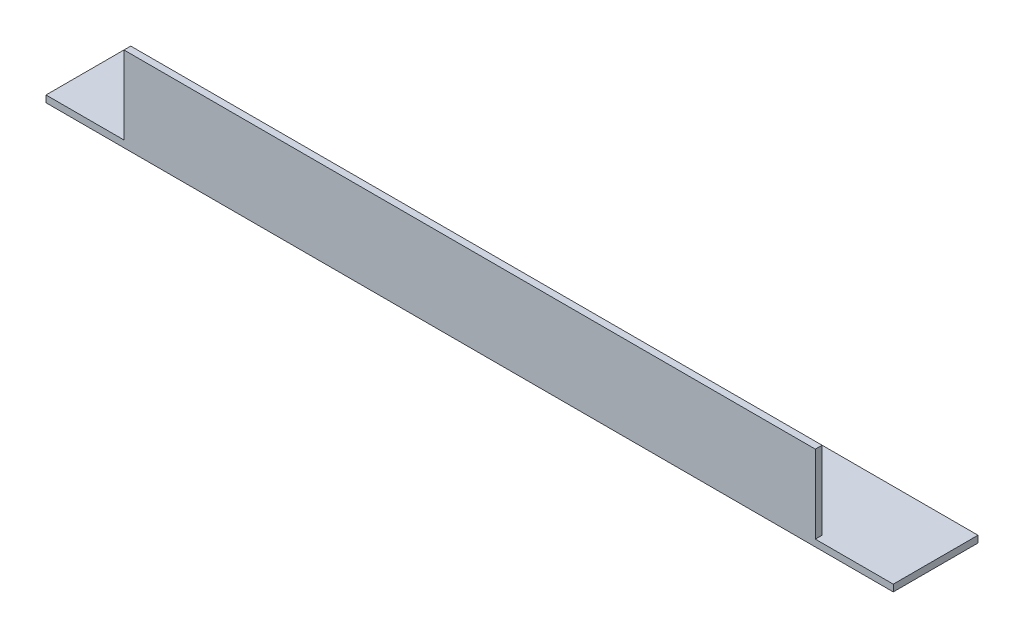
from build123d import *

# Parameters (mm, degrees)
EXTRUDE_1_DEPTH     = 250
SKETCH_2_W          = 23
SKETCH_2_H          = 23
CUT_EXTRUDE_1_DEPTH = 26


with BuildPart() as part:
    # Эскиз1 → Вытянуть-Тонкостенный1 (new body)
    with BuildSketch(Plane(origin=(0, 0, 0), x_dir=(0, 0, -1), z_dir=(1, 0, 0))):
        Polygon((0, 25), (0, 0), (25, 0), (25, 2), (2, 2), (2, 25), align=None)
    extrude(amount=EXTRUDE_1_DEPTH)

    # Эскиз2 → Вырез-Вытянуть1 (cut, through all)
    with BuildSketch(Plane.XY):
        with Locations((238.5, 13.5)):
            Rectangle(SKETCH_2_W, SKETCH_2_H)
        with Locations((11.5, 13.5)):
            Rectangle(SKETCH_2_W, SKETCH_2_H)
    extrude(amount=-CUT_EXTRUDE_1_DEPTH, mode=Mode.SUBTRACT)


solid = part.part
